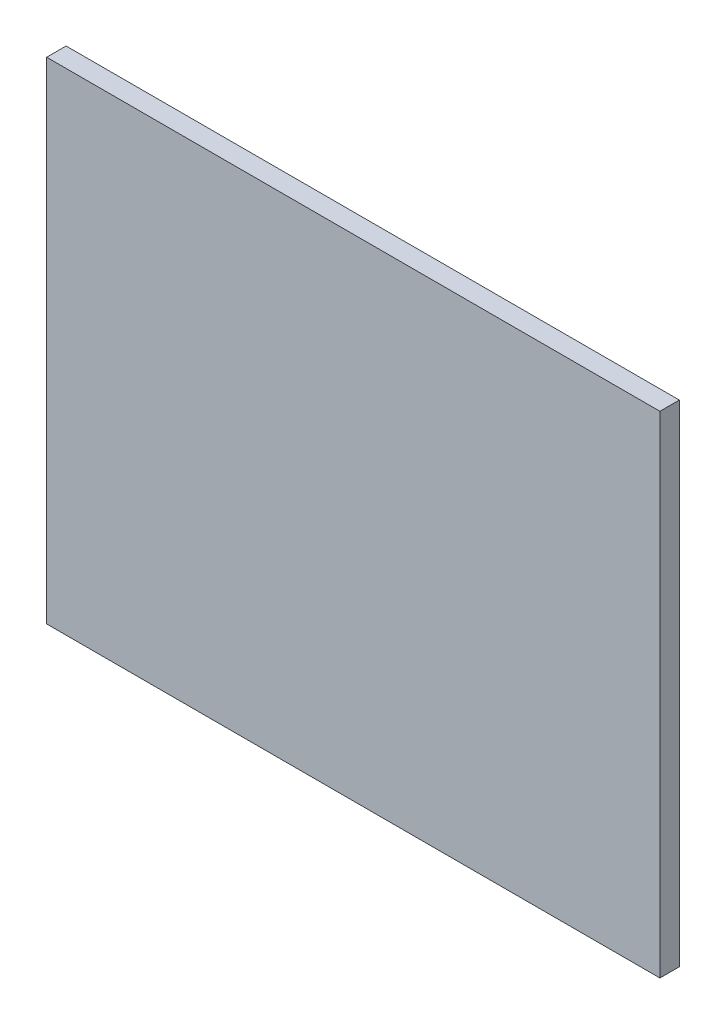
from build123d import *

# Parameters (mm, degrees)
SKETCH1_W           = 100.17
SKETCH1_H           = 80.17
BOSS_EXTRUDE1_DEPTH = 3.175


with BuildPart() as part:
    # Sketch1 → Boss-Extrude1 (new body)
    with BuildSketch(Plane.XY):
        Rectangle(SKETCH1_W, SKETCH1_H)
    extrude(amount=BOSS_EXTRUDE1_DEPTH)


solid = part.part
